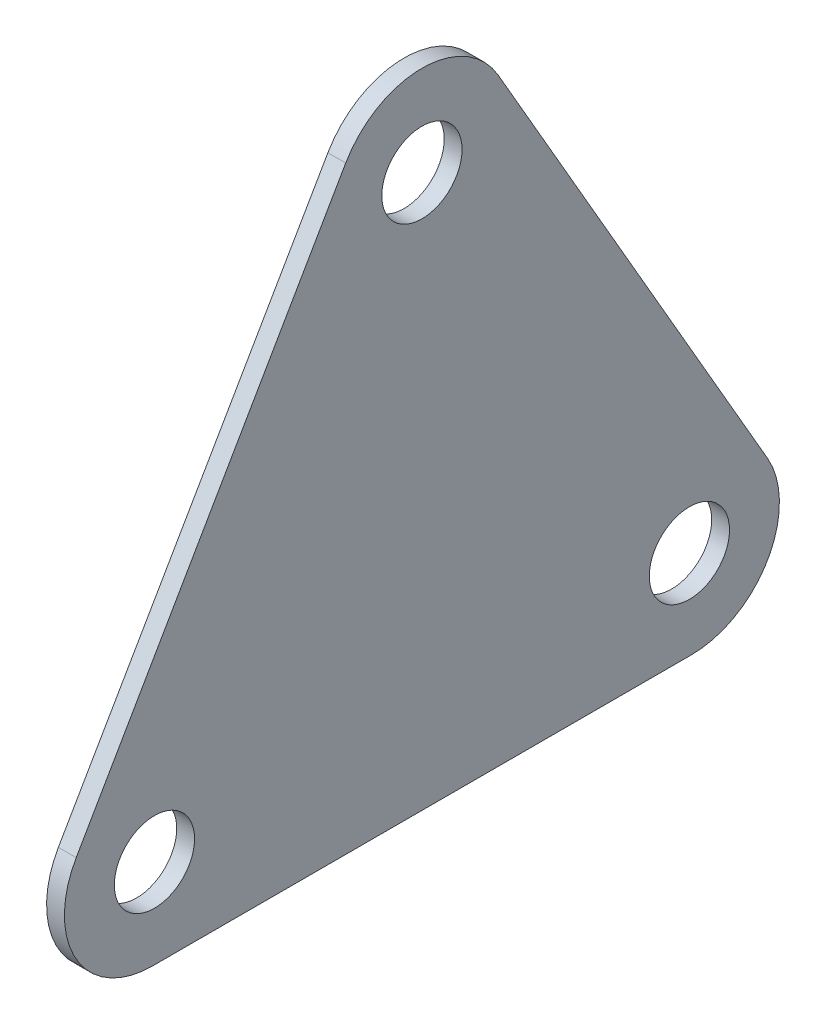
from build123d import *

# Parameters (mm, degrees)
SKETCH1_R           = 2.25
BOSS_EXTRUDE1_DEPTH = 1


with BuildPart() as part:
    # Sketch1 → Boss-Extrude1 (new body)
    with BuildSketch(Plane(origin=(0, 0, 0), x_dir=(0, 0, -1), z_dir=(1, 0, 0))):
        with BuildLine():
            Line((-13.770319446, -5), (16.45688661, -5))
            ThreePointArc((16.45688661, -5), (20.730212115, -2.532794369), (20.730212115, 2.401616892))
            Line((20.730212115, 2.401616892), (5.616609087, 28.579145222))
            ThreePointArc((5.616609087, 28.579145222), (1.343283582, 31.046350852), (-2.930041923, 28.579145222))
            Line((-2.930041923, 28.579145222), (-18.043644951, 2.401616892))
            ThreePointArc((-18.043644951, 2.401616892), (-18.043644951, -2.532794369), (-13.770319446, -5))
        make_face()
        with Locations((-13.656716418, 0)):
            Circle(SKETCH1_R, mode=Mode.SUBTRACT)
        with Locations((16.343283582, 0)):
            Circle(SKETCH1_R, mode=Mode.SUBTRACT)
        with Locations((1.343283582, 25.980762114)):
            Circle(SKETCH1_R, mode=Mode.SUBTRACT)
    extrude(amount=BOSS_EXTRUDE1_DEPTH)


solid = part.part
